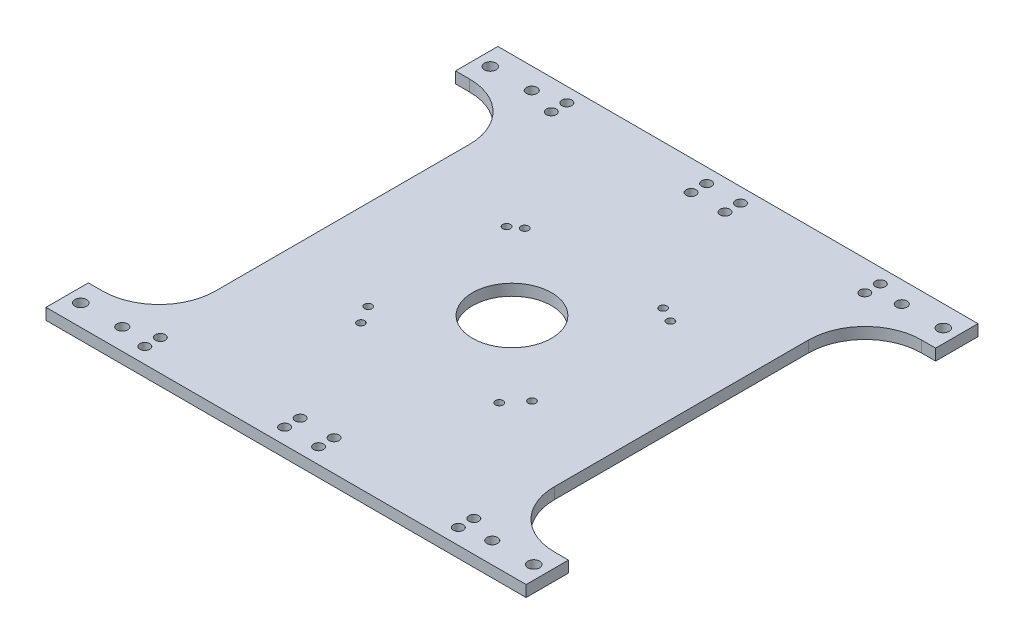
from build123d import *

# Parameters (mm, degrees)
SKETCH2_W             = 120
SKETCH2_H             = 160
SKETCH2_R             = 1.35
SKETCH2_R_2           = 14.002160315
BOSS_EXTRUDE1_DEPTH   = 4
SKETCH4_R             = 1.75
CUT_EXTRUDE1_DEPTH    = 4
SKETCH6_R             = 2.075123243
SKETCH6_R_2           = 1.889494125
BOSS_EXTRUDE2_DEPTH   = 4
BOSS_EXTRUDE2_2_DEPTH = 4
BOSS_EXTRUDE2_3_DEPTH = 4
BOSS_EXTRUDE2_4_DEPTH = 4


with BuildPart() as part:
    # Sketch2 → Boss-Extrude1 (new body)
    with BuildSketch(Plane(origin=(0, 0, 0), x_dir=(1, 0, 0), z_dir=(0, 1, 0))):
        Rectangle(SKETCH2_W, SKETCH2_H)
        with Locations((-28.228110793, 26.305779309)):
            Circle(SKETCH2_R, mode=Mode.SUBTRACT)
        with Locations((-28.228110793, -22.694220691)):
            Circle(SKETCH2_R, mode=Mode.SUBTRACT)
        with Locations((-24.5, -29)):
            Circle(SKETCH2_R, mode=Mode.SUBTRACT)
        with Locations((24.5, -29)):
            Circle(SKETCH2_R, mode=Mode.SUBTRACT)
        with Locations((29.771889207, -22.694220691)):
            Circle(SKETCH2_R, mode=Mode.SUBTRACT)
        with Locations((29.771889207, 26.305779309)):
            Circle(SKETCH2_R, mode=Mode.SUBTRACT)
        with Locations((24.5, 29)):
            Circle(SKETCH2_R, mode=Mode.SUBTRACT)
        with Locations((-24.5, 29)):
            Circle(SKETCH2_R, mode=Mode.SUBTRACT)
        Circle(SKETCH2_R_2, mode=Mode.SUBTRACT)
    extrude(amount=BOSS_EXTRUDE1_DEPTH)

    # Sketch4 → Cut-Extrude1 (cut)
    with BuildSketch(Plane(origin=(0, 4, 0), x_dir=(1, 0, 0), z_dir=(0, 1, 0))):
        with Locations((-6, 74.910885073)):
            Circle(SKETCH4_R)
        with Locations((-6, 69.410885073)):
            Circle(SKETCH4_R)
        with Locations((-55.5, 69.410885073)):
            Circle(SKETCH4_R)
        with Locations((-55.5, 74.910885073)):
            Circle(SKETCH4_R)
        with Locations((55.5, 74.910885073)):
            Circle(SKETCH4_R)
        with Locations((55.5, 69.410885073)):
            Circle(SKETCH4_R)
        with Locations((6, 69.410885073)):
            Circle(SKETCH4_R)
        with Locations((6, 74.910885073)):
            Circle(SKETCH4_R)
        with Locations((-6, -69)):
            Circle(SKETCH4_R)
        with Locations((-6, -74.5)):
            Circle(SKETCH4_R)
        with Locations((-55.5, -74.5)):
            Circle(SKETCH4_R)
        with Locations((-55.5, -69)):
            Circle(SKETCH4_R)
        with Locations((55.5, -69)):
            Circle(SKETCH4_R)
        with Locations((55.5, -74.5)):
            Circle(SKETCH4_R)
        with Locations((6, -74.5)):
            Circle(SKETCH4_R)
        with Locations((6, -69)):
            Circle(SKETCH4_R)
    extrude(amount=-CUT_EXTRUDE1_DEPTH, mode=Mode.SUBTRACT)


with BuildPart() as body_2:
    # Sketch6 → Boss-Extrude2 (new body)
    with BuildSketch(Plane(origin=(0, 4, 0), x_dir=(1, 0, 0), z_dir=(0, 1, 0))):
        with BuildLine():
            Line((60, 45), (60, 65))
            Line((60, 65), (60, 80))
            Line((60, 80), (85, 80))
            Line((85, 80), (85, 65))
            Line((85, 65), (80, 65))
            ThreePointArc((80, 65), (65.857864376, 59.142135624), (60, 45))
        make_face()
        with Locations((80.2, 72.5)):
            Circle(SKETCH6_R, mode=Mode.SUBTRACT)
        with Locations((65.5, 72.5)):
            Circle(SKETCH6_R_2, mode=Mode.SUBTRACT)
    extrude(amount=-BOSS_EXTRUDE2_DEPTH)


with BuildPart() as body_3:
    # Sketch6 → Boss-Extrude2 2 (new body)
    with BuildSketch(Plane(origin=(0, 4, 0), x_dir=(1, 0, 0), z_dir=(0, 1, 0))):
        with BuildLine():
            Line((-85, 80), (-85, 65))
            Line((-85, 65), (-80, 65))
            ThreePointArc((-80, 65), (-65.857864376, 59.142135624), (-60, 45))
            Line((-60, 45), (-60, 80))
            Line((-60, 80), (-85, 80))
        make_face()
        with Locations((-80.2, 72.5)):
            Circle(SKETCH6_R, mode=Mode.SUBTRACT)
        with Locations((-65.5, 72.5)):
            Circle(SKETCH6_R_2, mode=Mode.SUBTRACT)
    extrude(amount=-BOSS_EXTRUDE2_2_DEPTH)


with BuildPart() as body_4:
    # Sketch6 → Boss-Extrude2 3 (new body)
    with BuildSketch(Plane(origin=(0, 4, 0), x_dir=(1, 0, 0), z_dir=(0, 1, 0))):
        with BuildLine():
            Line((85, -80), (85, -65))
            Line((85, -65), (80, -65))
            ThreePointArc((80, -65), (65.857864376, -59.142135624), (60, -45))
            Line((60, -45), (60, -65))
            Line((60, -65), (60, -80))
            Line((60, -80), (85, -80))
        make_face()
        with Locations((65.5, -72.5)):
            Circle(SKETCH6_R_2, mode=Mode.SUBTRACT)
        with Locations((80.2, -72.5)):
            Circle(SKETCH6_R, mode=Mode.SUBTRACT)
    extrude(amount=-BOSS_EXTRUDE2_3_DEPTH)


with BuildPart() as body_5:
    # Sketch6 → Boss-Extrude2 4 (new body)
    with BuildSketch(Plane(origin=(0, 4, 0), x_dir=(1, 0, 0), z_dir=(0, 1, 0))):
        with BuildLine():
            Line((-60, -80), (-60, -45))
            ThreePointArc((-60, -45), (-65.857864376, -59.142135624), (-80, -65))
            Line((-80, -65), (-85, -65))
            Line((-85, -65), (-85, -80))
            Line((-85, -80), (-60, -80))
        make_face()
        with Locations((-65.5, -72.5)):
            Circle(SKETCH6_R_2, mode=Mode.SUBTRACT)
        with Locations((-80.2, -72.5)):
            Circle(SKETCH6_R, mode=Mode.SUBTRACT)
    extrude(amount=-BOSS_EXTRUDE2_4_DEPTH)


with BuildPart() as body_3_1:
    add(body_3.part)

    # Combine1: union part, body 2, body 4, body 5
    add(part.part)
    add(body_2.part)
    add(body_4.part)
    add(body_5.part)


solid = body_3_1.part
